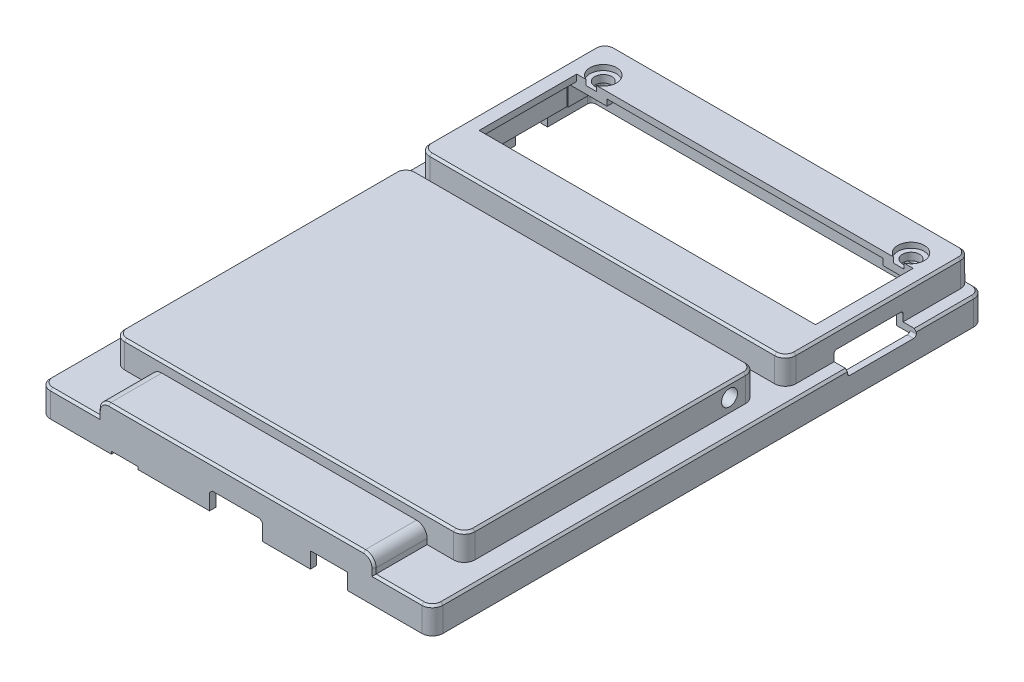
from build123d import *

# Parameters (mm, degrees)
SKETCH_1_W           = 74
SKETCH_1_H           = 104
EXTRUDE_1_DEPTH      = 5
SKETCH_2_W           = 52
SKETCH_2_H           = 65
EXTRUDE_2_DEPTH      = 3
SKETCH_4_W           = 69
SKETCH_4_H           = 35
EXTRUDE_4_DEPTH      = 5
SKETCH_5_W           = 66
SKETCH_5_H           = 55
EXTRUDE_5_DEPTH      = 5
FILLET_1_R           = 2
FILLET_2_R           = 2
SHELL_2_T            = -1.2
FILLET_4_R           = 2
FILLET_5_R           = 1
SKETCH_6_W           = 63.4
SKETCH_6_H           = 18.4
CUT_EXTRUDE_1_DEPTH  = 10
SKETCH_8_W           = 7.3
SKETCH_8_H           = 6.9
EXTRUDE_6_DEPTH      = 1.2
SKETCH_9_W           = 11
SKETCH_9_H           = 6.5
EXTRUDE_7_DEPTH      = 3.8
SKETCH_10_R          = 1.6
CUT_EXTRUDE_2_DEPTH  = 13
SKETCH_12_R          = 1.5
CUT_EXTRUDE_4_DEPTH  = 3.5
SKETCH_13_R          = 2.5
CUT_EXTRUDE_5_DEPTH  = 1
SKETCH_14_W          = 3.8
SKETCH_14_H          = 7
EXTRUDE_8_DEPTH      = 5
FILLET_6_R           = 1
SKETCH_15_W          = 9
SKETCH_15_H          = 4
SKETCH_15_W_2        = 13
SKETCH_15_H_2        = 5
CUT_EXTRUDE_6_DEPTH  = 5
FILLET_7_R           = 2
SKETCH_16_W          = 6
SKETCH_16_H          = 2
CUT_EXTRUDE_7_DEPTH  = 5
SKETCH_17_W          = 7
SKETCH_17_H          = 2
SKETCH_17_W_2        = 10
SKETCH_17_H_2        = 3.5
SKETCH_17_W_3        = 5
SKETCH_17_H_3        = 0.5
CUT_EXTRUDE_8_DEPTH  = 5
CHAMFER_1_SIZE       = 0.5
SKETCH_18_R          = 1.5
CUT_EXTRUDE_9_DEPTH  = 3.5
SKETCH_19_R          = 1.5
CUT_EXTRUDE_10_DEPTH = 3.5
SKETCH_20_W          = 18.4
SKETCH_20_H          = 5
CUT_EXTRUDE_11_DEPTH = 0.2
CHAMFER_2_SIZE       = 0.4
SKETCH_21_W          = 13
SKETCH_21_H          = 3
CUT_EXTRUDE_12_DEPTH = 10
FILLET_8_R           = 0.5
CHAMFER_5_SIZE       = 1


with BuildPart() as part:
    # 草图1 → 凸台-拉伸1 (new body)
    with BuildSketch(Plane(origin=(0, 0, 0), x_dir=(1, 0, 0), z_dir=(0, 1, 0))):
        Rectangle(SKETCH_1_W, SKETCH_1_H)
    extrude(amount=EXTRUDE_1_DEPTH)

    # 草图2 → 凸台-拉伸2 (add)
    with BuildSketch(Plane(origin=(0, 5, 0), x_dir=(1, 0, 0), z_dir=(0, 1, 0))):
        with Locations((0, -19.5)):
            Rectangle(SKETCH_2_W, SKETCH_2_H)
    extrude(amount=EXTRUDE_2_DEPTH)

    # 草图4 → 凸台-拉伸4 (add)
    with BuildSketch(Plane(origin=(0, 5, 0), x_dir=(1, 0, 0), z_dir=(0, 1, 0))):
        with Locations((0, 34.5)):
            Rectangle(SKETCH_4_W, SKETCH_4_H)
    extrude(amount=EXTRUDE_4_DEPTH)

    # 草图5 → 凸台-拉伸5 (add)
    with BuildSketch(Plane(origin=(0, 5, 0), x_dir=(1, 0, 0), z_dir=(0, 1, 0))):
        with Locations((0, -14.5)):
            Rectangle(SKETCH_5_W, SKETCH_5_H)
    extrude(amount=EXTRUDE_5_DEPTH)

    # 圆角1
    fillet_1_edges = [part.edges().sort_by_distance(p)[0] for p in [
        (37, 2.5, 52),
        (-37, 2.5, 52),
        (-37, 2.5, -52),
        (37, 2.5, -52),
    ]]
    fillet(fillet_1_edges, radius=FILLET_1_R)

    # 圆角2
    fillet_2_edges = [part.edges().sort_by_distance(p)[0] for p in [
        (-34.5, 7.5, -52),
        (-34.5, 7.5, -17),
        (34.5, 7.5, -17),
        (34.5, 7.5, -52),
        (-33, 7.5, 42),
        (33, 7.5, -13),
        (-33, 7.5, -13),
        (33, 7.5, 42),
    ]]
    fillet(fillet_2_edges, radius=FILLET_2_R)

    # 抽壳2
    shell_2_openings = [part.faces().sort_by_distance(p)[0] for p in [
        (0, 0, 0),
    ]]
    offset(amount=SHELL_2_T, openings=shell_2_openings, kind=Kind.INTERSECTION)

    # 圆角4
    fillet_4_edges = [part.edges().sort_by_distance(p)[0] for p in [
        (26, 8, 47),
        (-26, 8, 47),
    ]]
    fillet(fillet_4_edges, radius=FILLET_4_R)

    # 圆角5
    fillet_5_edges = [part.edges().sort_by_distance(p)[0] for p in [
        (-24.8, 6.8, 45.8),
        (24.8, 6.8, 45.8),
    ]]
    fillet(fillet_5_edges, radius=FILLET_5_R)

    # 草图6 → 切除-拉伸1 (cut)
    with BuildSketch(Plane(origin=(0, 10, 0), x_dir=(1, 0, 0), z_dir=(0, 1, 0))):
        with Locations((0, 34.7)):
            Rectangle(SKETCH_6_W, SKETCH_6_H)
    extrude(amount=-CUT_EXTRUDE_1_DEPTH, mode=Mode.SUBTRACT)

    # 草图8 → 凸台-拉伸6 (add)
    with BuildSketch(Plane.XZ.offset(-8.8)):
        with Locations((-29.65, -47.35)):
            Rectangle(SKETCH_8_W, SKETCH_8_H)
        with Locations((29.65, -47.35)):
            Rectangle(SKETCH_8_W, SKETCH_8_H)
    extrude(amount=EXTRUDE_6_DEPTH)

    # 草图9 → 凸台-拉伸7 (add)
    with BuildSketch(Plane.XZ.offset(-3.8)):
        with Locations((-30.3, 47.55)):
            Rectangle(SKETCH_9_W, SKETCH_9_H)
        with Locations((30.3, 47.55)):
            Rectangle(SKETCH_9_W, SKETCH_9_H)
    extrude(amount=EXTRUDE_7_DEPTH)

    # 草图10 → 切除-拉伸2 (cut)
    with BuildSketch(Plane(origin=(0, 10, 0), x_dir=(1, 0, 0), z_dir=(0, 1, 0))):
        with Locations((-29, 46.2)):
            Circle(SKETCH_10_R)
        with Locations((29, 46.2)):
            Circle(SKETCH_10_R)
    extrude(amount=-CUT_EXTRUDE_2_DEPTH, mode=Mode.SUBTRACT)

    # 草图12 → 切除-拉伸4 (cut)
    with BuildSketch(Plane.XZ):
        with Locations((-29, 48)):
            Circle(SKETCH_12_R)
        with Locations((29, 48)):
            Circle(SKETCH_12_R)
    extrude(amount=-CUT_EXTRUDE_4_DEPTH, mode=Mode.SUBTRACT)

    # 草图13 → 切除-拉伸5 (cut)
    with BuildSketch(Plane(origin=(0, 10, 0), x_dir=(1, 0, 0), z_dir=(0, 1, 0))):
        with Locations((-29, 46.2)):
            Circle(SKETCH_13_R)
        with Locations((29, 46.2)):
            Circle(SKETCH_13_R)
    extrude(amount=-CUT_EXTRUDE_5_DEPTH, mode=Mode.SUBTRACT)

    # 草图14 → 凸台-拉伸8 (add)
    with BuildSketch(Plane.XZ.offset(-3.8)):
        with Locations((-29.9, -8.3)):
            Rectangle(SKETCH_14_W, SKETCH_14_H)
        with Locations((29.9, -8.3)):
            Rectangle(SKETCH_14_W, SKETCH_14_H)
    extrude(amount=-EXTRUDE_8_DEPTH)

    # 圆角6
    fillet_6_edges = [part.edges().sort_by_distance(p)[0] for p in [
        (-31.8, 6.3, -4.8),
        (-28, 6.3, -4.8),
        (-28, 6.3, -11.8),
        (28, 6.3, -11.8),
        (28, 6.3, -4.8),
        (31.8, 6.3, -4.8),
    ]]
    fillet(fillet_6_edges, radius=FILLET_6_R)

    # 草图15 → 切除-拉伸6 (cut)
    with BuildSketch(Plane(origin=(0, 0, -52), x_dir=(-1, 0, 0), z_dir=(0, 0, -1))):
        with Locations((21.5, 5.8)):
            Rectangle(SKETCH_15_W, SKETCH_15_H)
        with Locations((9, 5.8)):
            Rectangle(SKETCH_15_W, SKETCH_15_H)
        with Locations((-20, 6.3)):
            Rectangle(SKETCH_15_W_2, SKETCH_15_H_2)
    extrude(amount=-CUT_EXTRUDE_6_DEPTH, mode=Mode.SUBTRACT)

    # 圆角7
    fillet_7_edges = [part.edges().sort_by_distance(p)[0] for p in [
        (-17, 3.8, -51.4),
        (-26, 3.8, -51.4),
        (-4.5, 3.8, -51.4),
        (-13.5, 3.8, -51.4),
        (26.5, 3.8, -51.4),
        (13.5, 3.8, -51.4),
    ]]
    fillet(fillet_7_edges, radius=FILLET_7_R)

    # 草图16 → 切除-拉伸7 (cut)
    with BuildSketch(Plane.ZY.offset(37)):
        with Locations((-39.5, 1)):
            Rectangle(SKETCH_16_W, SKETCH_16_H)
    extrude(amount=-CUT_EXTRUDE_7_DEPTH, mode=Mode.SUBTRACT)

    # 草图17 → 切除-拉伸8 (cut)
    with BuildSketch(Plane.XY.offset(52)):
        with Locations((17.5, 1)):
            Rectangle(SKETCH_17_W, SKETCH_17_H)
        with Locations((0, 1.75)):
            Rectangle(SKETCH_17_W_2, SKETCH_17_H_2)
        with Locations((-21, 0.25)):
            Rectangle(SKETCH_17_W_3, SKETCH_17_H_3)
    extrude(amount=-CUT_EXTRUDE_8_DEPTH, mode=Mode.SUBTRACT)

    # 倒角1
    chamfer_1_edges = [part.edges().sort_by_distance(p)[0] for p in [
        (5, 3.5, 51.4),
        (-5, 3.5, 51.4),
    ]]
    chamfer(chamfer_1_edges, length=CHAMFER_1_SIZE)

    # 草图18 → 切除-拉伸9 (cut)
    with BuildSketch(Plane.ZY.offset(33)):
        with Locations((-8, 7.5)):
            Circle(SKETCH_18_R)
    extrude(amount=-CUT_EXTRUDE_9_DEPTH, mode=Mode.SUBTRACT)

    # 草图19 → 切除-拉伸10 (cut)
    with BuildSketch(Plane(origin=(33, 0, 0), x_dir=(0, 0, -1), z_dir=(1, 0, 0))):
        with Locations((8, 7.5)):
            Circle(SKETCH_19_R)
    extrude(amount=-CUT_EXTRUDE_10_DEPTH, mode=Mode.SUBTRACT)

    # 草图20 → 切除-拉伸11 (cut)
    with BuildSketch(Plane(origin=(-33.3, 0, 0), x_dir=(0, 0, -1), z_dir=(1, 0, 0))):
        with Locations((34.7, 6.3)):
            Rectangle(SKETCH_20_W, SKETCH_20_H)
    extrude(amount=-CUT_EXTRUDE_11_DEPTH, mode=Mode.SUBTRACT)

    # 倒角2
    chamfer_2_edges = [part.edges().sort_by_distance(p)[0] for p in [
        (33, 10, 14.5),
        (-33, 10, 14.5),
        (0, 10, 42),
        (-32.414213562, 10, -12.414213562),
        (-32.414213562, 10, 41.414213562),
        (32.414213562, 10, 41.414213562),
        (32.414213562, 10, -12.414213562),
        (30.5, 5, 52),
        (0, 8, 52),
        (26, 5.5, 52),
        (-26, 5.5, 52),
        (-25.414213562, 7.414213562, 52),
        (25.414213562, 7.414213562, 52),
        (-33.75, 5, -52),
        (37, 5, 0),
        (-30.5, 5, 52),
        (33.75, 5, -52),
        (-37, 5, 0),
        (-36.414213562, 5, 51.414213562),
        (-36.414213562, 5, -51.414213562),
        (36.414213562, 5, -51.414213562),
        (36.414213562, 5, 51.414213562),
        (-34.5, 10, -34.5),
        (0, 10, -52),
        (0, 10, -17),
        (34.5, 10, -34.5),
        (-33.914213562, 10, -17.585786438),
        (33.914213562, 10, -17.585786438),
        (33.914213562, 10, -51.414213562),
        (-33.914213562, 10, -51.414213562),
        (0, 10, -13),
    ]]
    chamfer(chamfer_2_edges, length=CHAMFER_2_SIZE)

    # 草图21 → 切除-拉伸12 (cut)
    with BuildSketch(Plane.ZY.offset(-33.3)):
        with Locations((-32.7, 5.3)):
            Rectangle(SKETCH_21_W, SKETCH_21_H)
    extrude(amount=-CUT_EXTRUDE_12_DEPTH, mode=Mode.SUBTRACT)

    # 圆角8
    fillet_8_edges = [part.edges().sort_by_distance(p)[0] for p in [
        (36.4, 3.8, -26.2),
        (33.9, 6.8, -39.2),
        (36.4, 3.8, -39.2),
        (33.9, 6.8, -26.2),
    ]]
    fillet(fillet_8_edges, radius=FILLET_8_R)

    # 倒角5
    chamfer_5_edges = [part.edges().sort_by_distance(p)[0] for p in [
        (17.5, 2, 52),
    ]]
    chamfer(chamfer_5_edges, length=CHAMFER_5_SIZE)


solid = part.part
